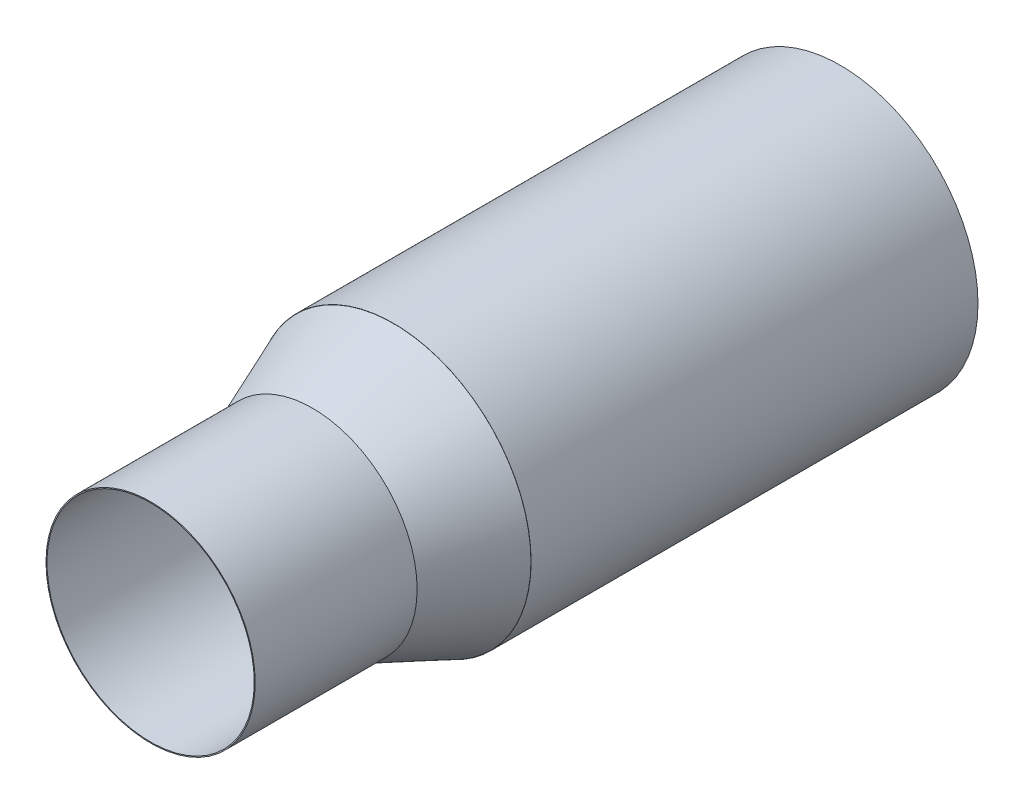
from build123d import *

# Parameters (mm, degrees)
SKETCH1_R           = 21.59
SKETCH1_R_2         = 9.144
BOSS_EXTRUDE1_DEPTH = 70.1
SKETCH2_R           = 16.4084
SKETCH2_R_2         = 16.256
BOSS_EXTRUDE2_DEPTH = 38.1


with BuildPart() as part:
    # Sketch1 → Boss-Extrude1 (new body)
    with BuildSketch(Plane.XY):
        Circle(SKETCH1_R)
        with Locations((0.118855304, -11.557)):
            Circle(SKETCH1_R_2, mode=Mode.SUBTRACT)
        with Locations((9.955579479, 5.869470694)):
            Circle(SKETCH1_R_2, mode=Mode.SUBTRACT)
        with Locations((-10.060900468, 5.687049391)):
            Circle(SKETCH1_R_2, mode=Mode.SUBTRACT)
    extrude(amount=BOSS_EXTRUDE1_DEPTH)

    # Sketch2 → Boss-Extrude2 (add)
    with BuildSketch(Plane.XY.offset(70.1)):
        Circle(SKETCH2_R)
        Circle(SKETCH2_R_2, mode=Mode.SUBTRACT)
    extrude(amount=BOSS_EXTRUDE2_DEPTH)

    # Sketch8 → Revolve3 (revolve)
    with BuildSketch(Plane(origin=(0, 0, 0), x_dir=(0, 0, -1), z_dir=(1, 0, 0))):
        Polygon((-70.1, 21.56234654), (-82.8, 16.4084), (-70.1, 16.4084), align=None)
    revolve(axis=Axis((0, 0, 126.159811209), (0, 0, -1)))


solid = part.part
